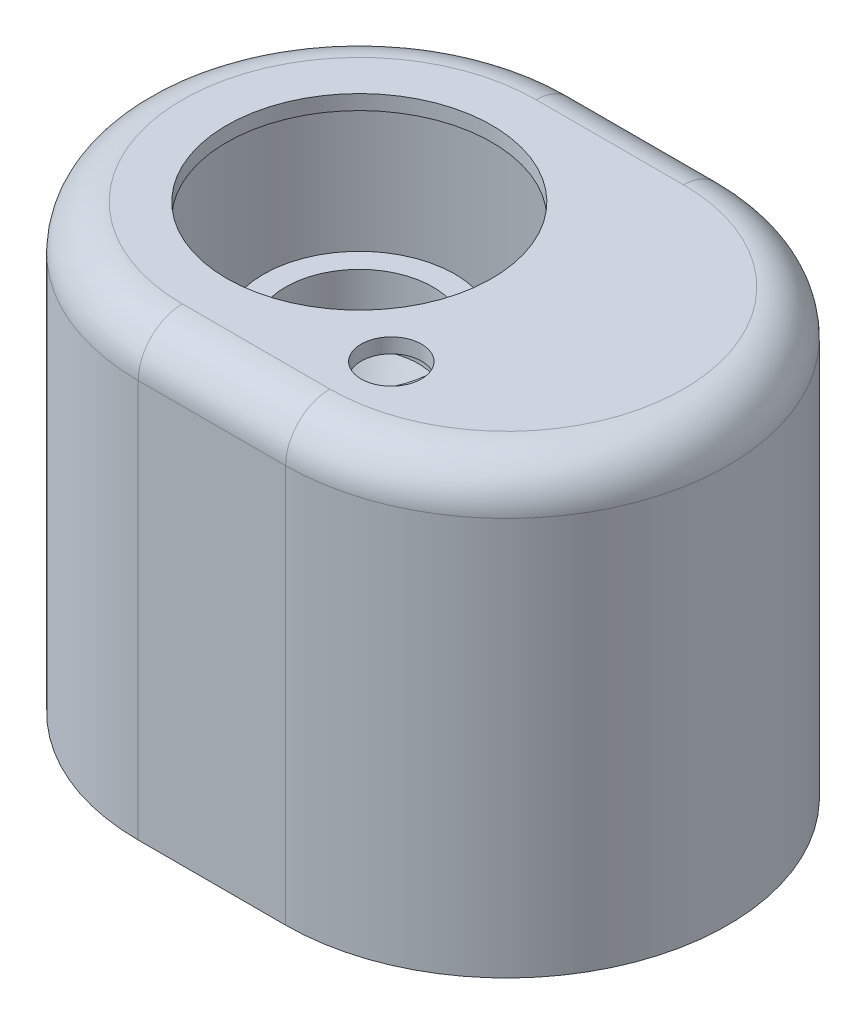
from build123d import *

# Parameters (mm, degrees)
EXTRUDE_2_DEPTH      = 60
EXTRUDE_2_DEPTH_BACK = 0.0001
FILLET_2_R           = 6
SHELL_2_T            = -2
CUT_EXTRUDE_1_REACH  = 85.666
SKETCH_3_R           = 18
EXTRUDE_5_REACH      = 69.099
SKETCH_5_R           = 1.5
SKETCH_5_R_2         = 1.611386823
SKETCH_6_R           = 4.1
CUT_EXTRUDE_2_DEPTH  = 2
EXTRUDE_START        = -2
EXTRUDE_6_DEPTH      = 4


with BuildPart() as part:
    # 草图2 → 凸台-拉伸2 (new, two sides)
    with BuildSketch(Plane(origin=(0, 0, 0), x_dir=(1, 0, 0), z_dir=(0, 1, 0))) as extrude_2_sk:
        with BuildLine():
            Line((0, 30), (20, 30))
            ThreePointArc((20, 30), (50, 0), (20, -30))
            Line((20, -30), (0, -30))
            ThreePointArc((0, -30), (-30, 0), (0, 30))
        make_face()
    extrude(amount=EXTRUDE_2_DEPTH)
    extrude(extrude_2_sk.sketch, amount=-EXTRUDE_2_DEPTH_BACK)

    # 圆角2
    fillet_2_edges = [part.edges().sort_by_distance(p)[0] for p in [
        (-30, 60, 0),
        (10, 60, 30),
        (50, 60, 0),
        (10, 60, -30),
    ]]
    fillet(fillet_2_edges, radius=FILLET_2_R)

    # 抽壳2
    shell_2_openings = [part.faces().sort_by_distance(p)[0] for p in [
        (10, -0.0001, 0),
    ]]
    offset(amount=SHELL_2_T, openings=shell_2_openings, kind=Kind.INTERSECTION)

    # 草图3 → 切除-拉伸1 (cut, up to next)
    with BuildSketch(Plane(origin=(0, 60, 0), x_dir=(1, 0, 0), z_dir=(0, 1, 0)), mode=Mode.PRIVATE) as cut_extrude_1_sk1:
        with Locations(Location((0, 0, 0), (0, 0, 270))):
            Circle(SKETCH_3_R)
    cut_extrude_1_tool1 = extrude(cut_extrude_1_sk1.sketch, amount=-CUT_EXTRUDE_1_REACH, mode=Mode.PRIVATE) & part.part
    add(cut_extrude_1_tool1.solids().sort_by_distance((0, 60, 0))[0], mode=Mode.SUBTRACT)

    # 草图5 → 凸台-拉伸5 (add, up to next)
    with BuildSketch(Plane(origin=(0, 33.2, 0), x_dir=(1, 0, 0), z_dir=(0, 1, 0)), mode=Mode.PRIVATE) as extrude_5_sk1:
        with BuildLine():
            Line((34.15, -26.453307922), (34.15, -19.5))
            ThreePointArc((34.15, -19.5), (31, -16.35), (27.85, -19.5))
            Line((27.85, -19.5), (27.85, -28.954749179))
            ThreePointArc((27.85, -28.954749179), (31.070876302, -27.882533922), (34.15, -26.453307922))
        make_face()
        with Locations(Location((31, -19.5, 0), (0, 0, 270))):
            Circle(SKETCH_5_R, mode=Mode.SUBTRACT)
    extrude_5_tool1 = extrude(extrude_5_sk1.sketch, amount=EXTRUDE_5_REACH, mode=Mode.PRIVATE) - part.part
    # 草图5 → 凸台-拉伸5 (add, up to next)
    with BuildSketch(Plane(origin=(0, 33.2, 0), x_dir=(1, 0, 0), z_dir=(0, 1, 0)), mode=Mode.PRIVATE) as extrude_5_sk2:
        with BuildLine():
            Line((34.15, 19.5), (34.15, 26.453307922))
            ThreePointArc((34.15, 26.453307922), (31.070876302, 27.882533922), (27.85, 28.954749179))
            Line((27.85, 28.954749179), (27.85, 19.5))
            ThreePointArc((27.85, 19.5), (31, 16.35), (34.15, 19.5))
        make_face()
        with Locations(Location((31, 19.5, 0), (0, 0, 270))):
            Circle(SKETCH_5_R_2, mode=Mode.SUBTRACT)
    extrude_5_tool2 = extrude(extrude_5_sk2.sketch, amount=EXTRUDE_5_REACH, mode=Mode.PRIVATE) - part.part
    add(extrude_5_tool1.solids().sort_by_distance((30.864931, 33.2, 22.774956))[0])
    add(extrude_5_tool2.solids().sort_by_distance((30.862479, 33.2, -22.834401))[0])

    # 草图6 → 切除-拉伸2 (cut)
    with BuildSketch(Plane(origin=(0, 60, 0), x_dir=(1, 0, 0), z_dir=(0, 1, 0))):
        with Locations(Location((20.936876077, -16.594048798, 0), (0, 0, 270))):
            Circle(SKETCH_6_R)
    extrude(amount=-CUT_EXTRUDE_2_DEPTH, mode=Mode.SUBTRACT)

    # 草图8 → 凸台-拉伸6 (add)
    with BuildSketch(Plane.XZ.offset(0.0001).offset(EXTRUDE_START)):
        with BuildLine():
            Line((20, -28), (0, -28))
            ThreePointArc((0, -28), (-28, 0), (0, 28))
            Line((0, 28), (20, 28))
            ThreePointArc((20, 28), (48, 0), (20, -28))
        make_face()
        with BuildLine():
            ThreePointArc((20, -26.5), (46.5, 0), (20, 26.5))
            Line((20, 26.5), (0, 26.5))
            ThreePointArc((0, 26.5), (-26.5, 0), (0, -26.5))
            Line((0, -26.5), (20, -26.5))
        make_face(mode=Mode.SUBTRACT)
    extrude(amount=-EXTRUDE_6_DEPTH)


with BuildPart() as body_2:
    # 草图4 → 旋转3 (revolve)
    with BuildSketch(Plane.XY, mode=Mode.PRIVATE) as revolve_3_sk:
        Polygon((-10, 45), (-10, 39), (-8, 39), (-8, 37), (-4.5, 30), (-6.5, 30), (-6.5, 26), (-9.5, 26), (-9.5, 31.05572809), (-13, 38.05572809), (-13, 45), align=None)
    revolve(revolve_3_sk.sketch.rotate(Axis((0, 72.773070172, 0), (0, -1, 0)), 270), axis=Axis((0, 72.773070172, 0), (0, -1, 0)))


solid = Compound([part.part, body_2.part])
